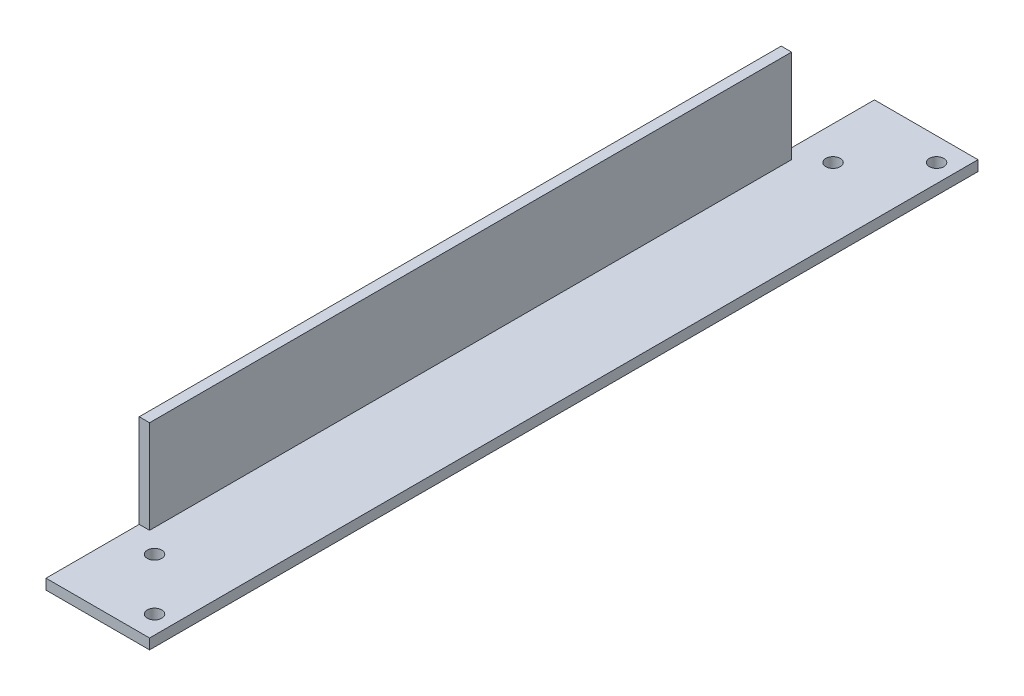
from build123d import *

# Parameters (mm, degrees)
BOSS_EXTRU_1_DEPTH      = 160
ESQUISSE2_W             = 18
ESQUISSE2_H             = 18
ENL_V_MAT_EXTRU_1_DEPTH = 3
ESQUISSE6_R             = 1.4
ENL_V_MAT_EXTRU_5_DEPTH = 3


with BuildPart() as part:
    # Esquisse1 → Boss.-Extru.1 (new body)
    with BuildSketch(Plane.XY):
        Polygon((0, 0), (20, 0), (20, 2), (2, 2), (2, 20), (0, 20), align=None)
    extrude(amount=BOSS_EXTRU_1_DEPTH)

    # Esquisse2 → Enlèv. mat.-Extru.1 (cut, through all)
    with BuildSketch(Plane(origin=(2, 0, 0), x_dir=(0, 0, -1), z_dir=(1, 0, 0))):
        with Locations((-151, 11)):
            Rectangle(ESQUISSE2_W, ESQUISSE2_H)
        with Locations((-9, 11)):
            Rectangle(ESQUISSE2_W, ESQUISSE2_H)
    extrude(amount=-ENL_V_MAT_EXTRU_1_DEPTH, mode=Mode.SUBTRACT)

    # Esquisse6 → Enlèv. mat.-Extru.5 (cut, through all)
    with BuildSketch(Plane(origin=(0, 2, 0), x_dir=(1, 0, 0), z_dir=(0, 1, 0))):
        with Locations((6.48, -145.52)):
            Circle(ESQUISSE6_R)
        with Locations((6.48, -14.48)):
            Circle(ESQUISSE6_R)
        with Locations((16.48, -155.52)):
            Circle(ESQUISSE6_R)
        with Locations((16.48, -4.48)):
            Circle(ESQUISSE6_R)
    extrude(amount=-ENL_V_MAT_EXTRU_5_DEPTH, mode=Mode.SUBTRACT)


solid = part.part
